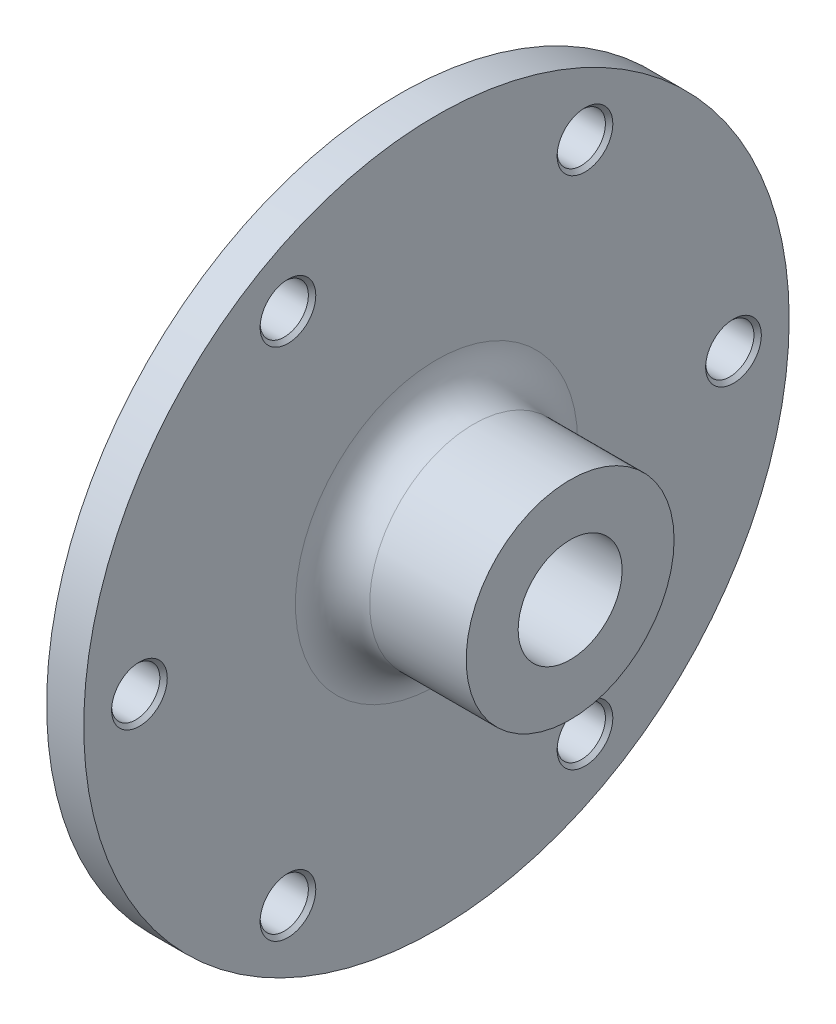
from build123d import *

# Parameters (mm, degrees)
FILLET1_R                                            = 5
CSK_FOR_M12_HEX_SOCKET_COUNTERSUNK_CAP_S_D           = 14
CSK_FOR_M12_HEX_SOCKET_COUNTERSUNK_CAP_S_CSINK_D     = 26
CSK_FOR_M12_HEX_SOCKET_COUNTERSUNK_CAP_S_CSINK_ANGLE = 90
CSK_FOR_M6_HEX_SOCKET_COUNTERSUNK_CAP_SC_D           = 6.5
CSK_FOR_M6_HEX_SOCKET_COUNTERSUNK_CAP_SC_CSINK_D     = 7.5
CSK_FOR_M6_HEX_SOCKET_COUNTERSUNK_CAP_SC_CSINK_ANGLE = 90
CIRPATTERN1_COUNT                                    = 6


with BuildPart() as part:
    # Sketch1 → Revolve1 (revolve)
    with BuildSketch(Plane.XY):
        Polygon((0, 0), (-28, 0), (-28, 35), (-23, 35), (-23, 47.5), (-18, 47.5), (-18, 14), (0, 14), align=None)
    revolve(axis=Axis((0, 0, 0), (-1, 0, 0)))

    # Fillet1
    fillet1_edges = [part.edges().sort_by_distance(p)[0] for p in [
        (-18, -14, 0),
    ]]
    fillet(fillet1_edges, radius=FILLET1_R)

    # CSK for M12 Hex Socket Countersunk Cap Screw1 (through all)
    with Locations(Plane.ZY.offset(28)):
        with Locations((0, 0)):
            CounterSinkHole(CSK_FOR_M12_HEX_SOCKET_COUNTERSUNK_CAP_S_D / 2, CSK_FOR_M12_HEX_SOCKET_COUNTERSUNK_CAP_S_CSINK_D / 2, counter_sink_angle=CSK_FOR_M12_HEX_SOCKET_COUNTERSUNK_CAP_S_CSINK_ANGLE)

    # CSK for M6 Hex Socket Countersunk Cap Screw1 (through all)
    with Locations(Plane(origin=(-18, 0, 0), x_dir=(0, 0, -1), z_dir=(1, 0, 0))):
        with Locations((-40, 0)):
            csk_for_m6_hex_socket_countersunk_cap_sc = CounterSinkHole(CSK_FOR_M6_HEX_SOCKET_COUNTERSUNK_CAP_SC_D / 2, CSK_FOR_M6_HEX_SOCKET_COUNTERSUNK_CAP_SC_CSINK_D / 2, counter_sink_angle=CSK_FOR_M6_HEX_SOCKET_COUNTERSUNK_CAP_SC_CSINK_ANGLE)

    # CirPattern1: CSK for M6 Hex Socket Countersunk Cap Screw1 ×6 about axis
    cirpattern1_axis = Axis((0, 0, 0), (1, 0, 0))
    for i in range(1, CIRPATTERN1_COUNT):
        add(csk_for_m6_hex_socket_countersunk_cap_sc.rotate(cirpattern1_axis, i * 360 / CIRPATTERN1_COUNT), mode=Mode.SUBTRACT)


solid = part.part
